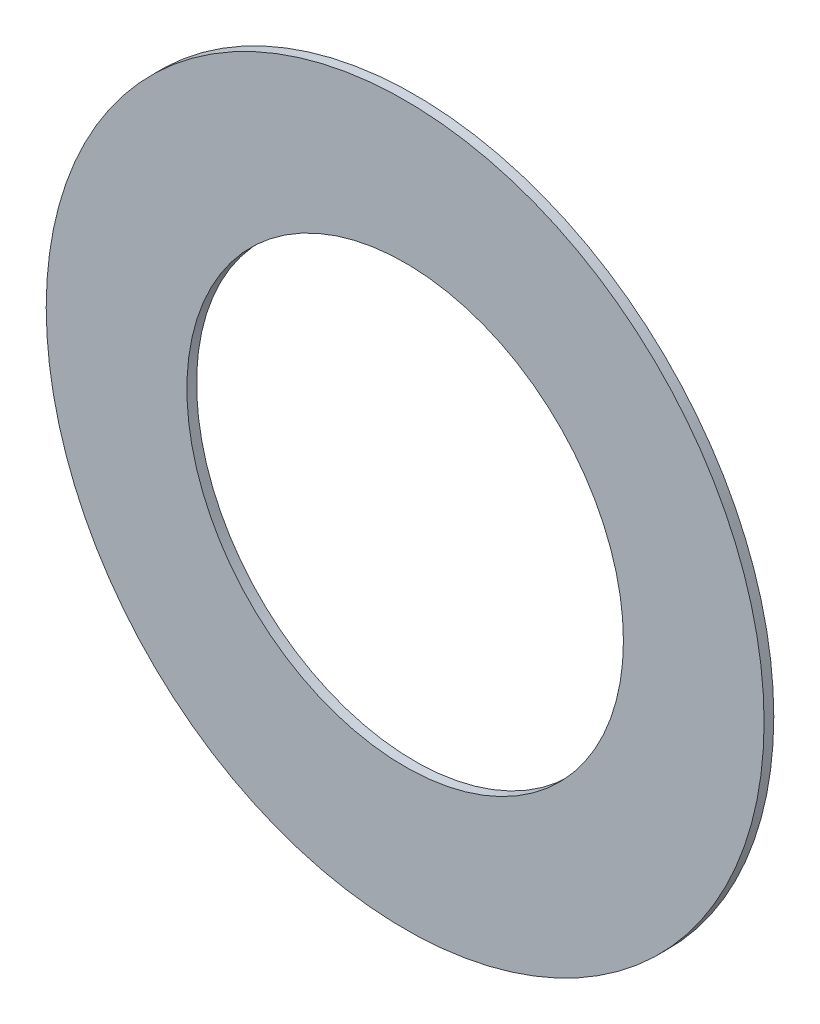
from build123d import *

# Parameters (mm, degrees)
SKETCH_1_R      = 37
SKETCH_1_R_2    = 22.5
EXTRUDE_1_DEPTH = 1


with BuildPart() as part:
    # Эскиз1 → Бобышка-Вытянуть1 (new body)
    with BuildSketch(Plane.XY):
        Circle(SKETCH_1_R)
        Circle(SKETCH_1_R_2, mode=Mode.SUBTRACT)
    extrude(amount=EXTRUDE_1_DEPTH)


solid = part.part
